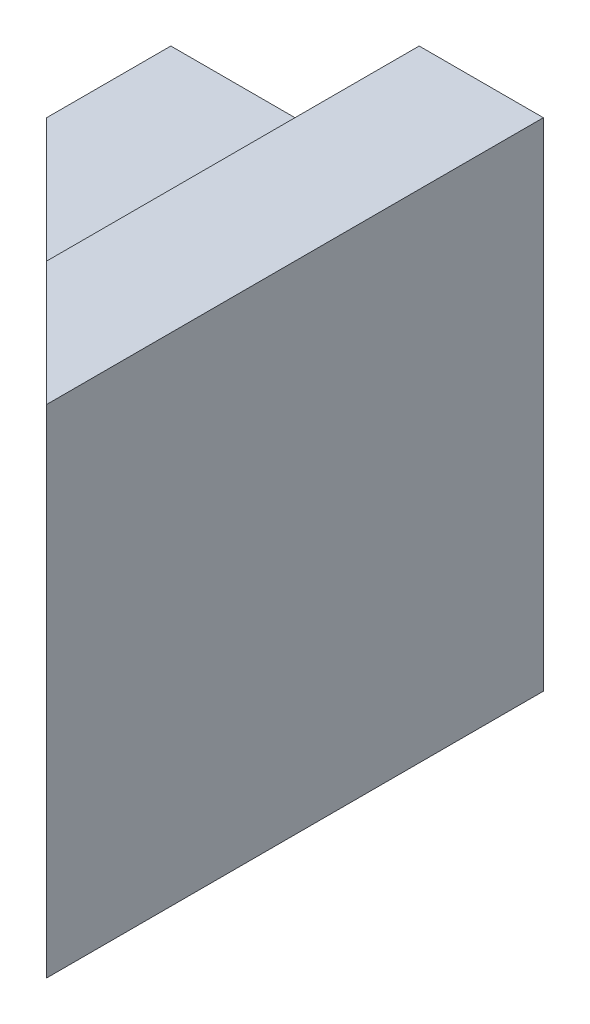
from build123d import *

# Parameters (mm, degrees)
BOSS_EXTRUDE1_DEPTH = 4
CUT_EXTRUDE1_DEPTH  = 10


with BuildPart() as part:
    # Sketch1 → Boss-Extrude1 (new body)
    with BuildSketch(Plane.XY):
        Polygon((0, 0), (0, 2), (1, 2), (1, 3), (3, 3), (3, 4), (4, 4), (4, 0), (3, 0), (3, 1), (1, 1), (1, 0), align=None)
    extrude(amount=BOSS_EXTRUDE1_DEPTH)

    # Sketch2 → Cut-Extrude1 (cut)
    with BuildSketch(Plane(origin=(0, 4, 0), x_dir=(1, 0, 0), z_dir=(0, 1, 0))):
        Polygon((0, 0), (4, -4), (0, -4), align=None)
    extrude(amount=-CUT_EXTRUDE1_DEPTH, mode=Mode.SUBTRACT)


solid = part.part
